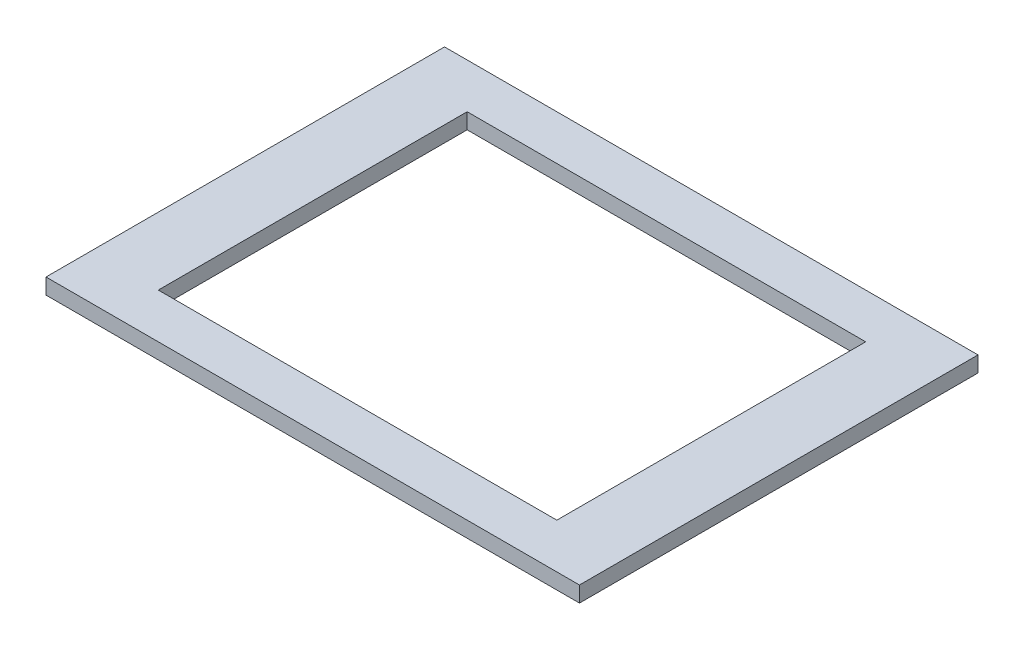
from build123d import *

# Parameters (mm, degrees)
SKETCH1_W           = 340
SKETCH1_H           = 254
BOSS_EXTRUDE1_DEPTH = 5
CUT_EXTRUDE1_REACH  = 12
SKETCH2_W           = 254
SKETCH2_H           = 196.85


with BuildPart() as part:
    # Sketch1 → Boss-Extrude1 (new body, symmetric)
    with BuildSketch(Plane(origin=(0, 0, 0), x_dir=(1, 0, 0), z_dir=(0, 1, 0))):
        Rectangle(SKETCH1_W, SKETCH1_H)
    extrude(amount=BOSS_EXTRUDE1_DEPTH, both=True)

    # Sketch2 → Cut-Extrude1 (cut, up to next)
    with BuildSketch(Plane(origin=(0, 5, 0), x_dir=(1, 0, 0), z_dir=(0, 1, 0)), mode=Mode.PRIVATE) as cut_extrude1_sk1:
        Rectangle(SKETCH2_W, SKETCH2_H)
    cut_extrude1_tool1 = extrude(cut_extrude1_sk1.sketch, amount=-CUT_EXTRUDE1_REACH, mode=Mode.PRIVATE) & part.part
    add(cut_extrude1_tool1.solids().sort_by_distance((0, 5, 0))[0], mode=Mode.SUBTRACT)


solid = part.part
